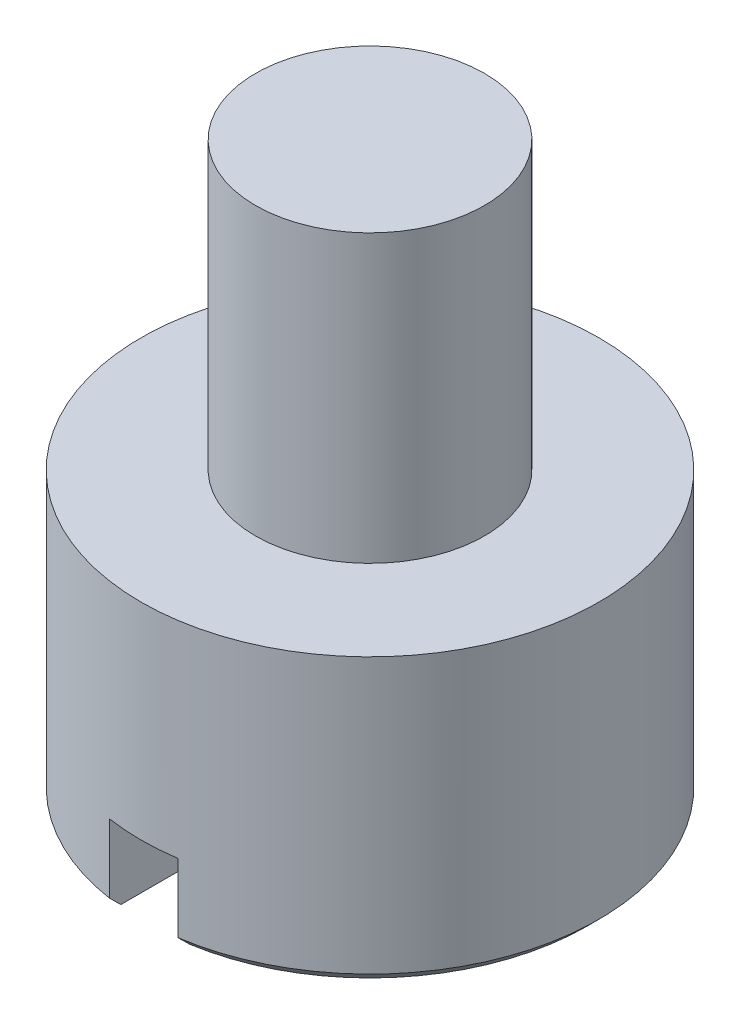
from build123d import *

# Parameters (mm, degrees)
SKETCH2_R               = 1
BOSS_EXTRUDE1_DEPTH     = 1.25
SKETCH3_R               = 0.5
BOSS_EXTRUDE2_DEPTH     = 1.25
CHAMFER1_SIZE           = 0.05
SKETCH4_W               = 0.3
SKETCH4_H               = 0.35
CUT_EXTRUDE1_DEPTH      = 2
CUT_EXTRUDE1_DEPTH_BACK = 2


with BuildPart() as part:
    # Sketch2 → Boss-Extrude1 (new body)
    with BuildSketch(Plane(origin=(0, 0, 0), x_dir=(1, 0, 0), z_dir=(0, 1, 0))):
        Circle(SKETCH2_R)
    extrude(amount=BOSS_EXTRUDE1_DEPTH)

    # Sketch3 → Boss-Extrude2 (add)
    with BuildSketch(Plane(origin=(0, 1.25, 0), x_dir=(1, 0, 0), z_dir=(0, 1, 0))):
        Circle(SKETCH3_R)
    extrude(amount=BOSS_EXTRUDE2_DEPTH)

    # Chamfer1
    chamfer1_edges = [part.edges().sort_by_distance(p)[0] for p in [
        (-1, 0, 0),
    ]]
    chamfer(chamfer1_edges, length=CHAMFER1_SIZE)

    # Sketch4 → Cut-Extrude1 (cut, two sides)
    with BuildSketch(Plane.XY) as cut_extrude1_sk:
        with Locations((0, 0.175)):
            Rectangle(SKETCH4_W, SKETCH4_H)
    extrude(amount=CUT_EXTRUDE1_DEPTH, mode=Mode.SUBTRACT)
    extrude(cut_extrude1_sk.sketch, amount=-CUT_EXTRUDE1_DEPTH_BACK, mode=Mode.SUBTRACT)


solid = part.part
